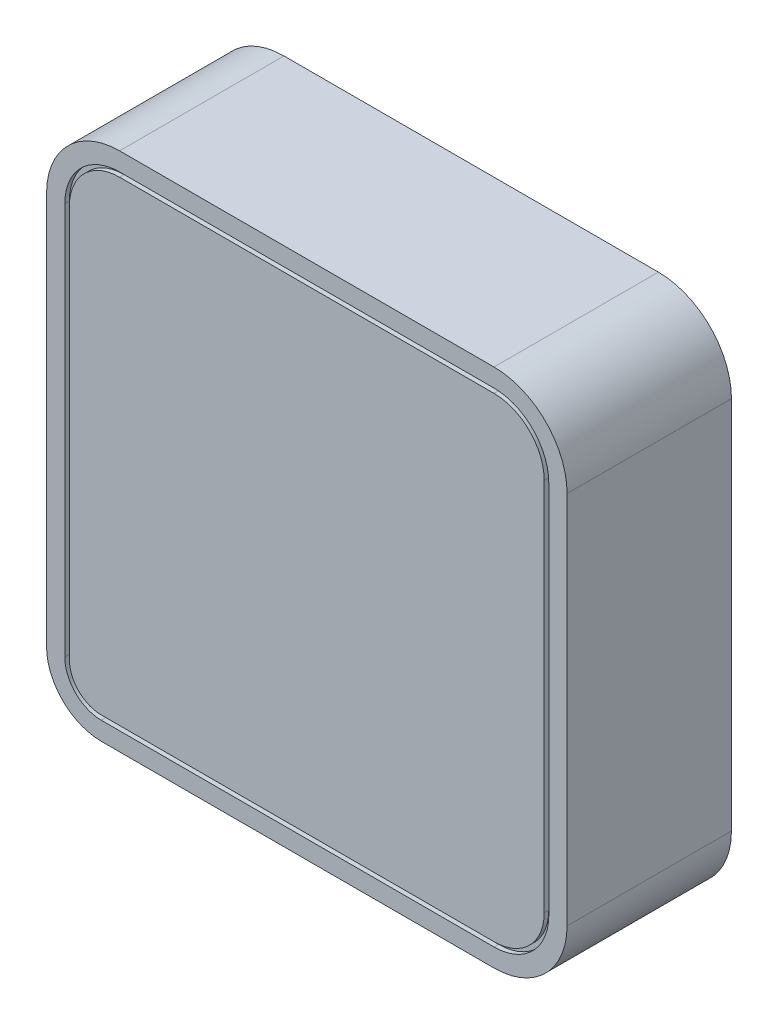
from build123d import *

# Parameters (mm, degrees)
SALIENTE_EXTRUIR1_DEPTH = 18
CORTAR_EXTRUIR1_DEPTH   = 0.5
CROQUIS3_R              = 1.25
CROQUIS3_W              = 12
CROQUIS3_H              = 15
CORTAR_EXTRUIR2_DEPTH   = 0.5


with BuildPart() as part:
    # Croquis1 → Saliente-Extruir1 (new body)
    with BuildSketch(Plane.XY):
        with BuildLine():
            Line((20.5, -28.5), (-22.5, -28.5))
            ThreePointArc((-22.5, -28.5), (-26.742640687, -26.742640687), (-28.5, -22.5))
            Line((-28.5, -22.5), (-28.5, 20.5))
            ThreePointArc((-28.5, 20.5), (-26.156854249, 26.156854249), (-20.5, 28.5))
            Line((-20.5, 28.5), (20.5, 28.5))
            ThreePointArc((20.5, 28.5), (26.156854249, 26.156854249), (28.5, 20.5))
            Line((28.5, 20.5), (28.5, -20.5))
            ThreePointArc((28.5, -20.5), (26.156854249, -26.156854249), (20.5, -28.5))
        make_face()
    extrude(amount=SALIENTE_EXTRUIR1_DEPTH)

    # Croquis2 → Cortar-Extruir1 (cut)
    with BuildSketch(Plane.XY.offset(18)):
        with BuildLine():
            Line((20.5, 26.5), (-20.5, 26.5))
            ThreePointArc((-20.5, 26.5), (-24.742640687, 24.742640687), (-26.5, 20.5))
            Line((-26.5, 20.5), (-26.5, -22.5))
            ThreePointArc((-26.5, -22.5), (-25.328427125, -25.328427125), (-22.5, -26.5))
            Line((-22.5, -26.5), (20.5, -26.5))
            ThreePointArc((20.5, -26.5), (24.742640687, -24.742640687), (26.5, -20.5))
            Line((26.5, -20.5), (26.5, 20.5))
            ThreePointArc((26.5, 20.5), (24.742640687, 24.742640687), (20.5, 26.5))
        make_face()
        with BuildLine():
            Line((-26, 20.5), (-26, -22.5))
            ThreePointArc((-26, -22.5), (-24.974873734, -24.974873734), (-22.5, -26))
            Line((-22.5, -26), (20.5, -26))
            ThreePointArc((20.5, -26), (24.389087297, -24.389087297), (26, -20.5))
            Line((26, -20.5), (26, 20.5))
            ThreePointArc((26, 20.5), (24.389087297, 24.389087297), (20.5, 26))
            Line((20.5, 26), (-20.5, 26))
            ThreePointArc((-20.5, 26), (-24.389087297, 24.389087297), (-26, 20.5))
        make_face(mode=Mode.SUBTRACT)
    extrude(amount=-CORTAR_EXTRUIR1_DEPTH, mode=Mode.SUBTRACT)

    # Croquis3 → Cortar-Extruir2 (cut)
    with BuildSketch(Plane.ZY.offset(28.5)):
        with Locations((7.75, -18.4)):
            Circle(CROQUIS3_R)
        with Locations((9, 9)):
            Rectangle(CROQUIS3_W, CROQUIS3_H)
        Polygon((9, -3.5), (7.3, -3.5), (5.7, -5.1), (5.7, -10.3), (7.3, -11.9), (9, -11.9), align=None)
    extrude(amount=-CORTAR_EXTRUIR2_DEPTH, mode=Mode.SUBTRACT)


solid = part.part
